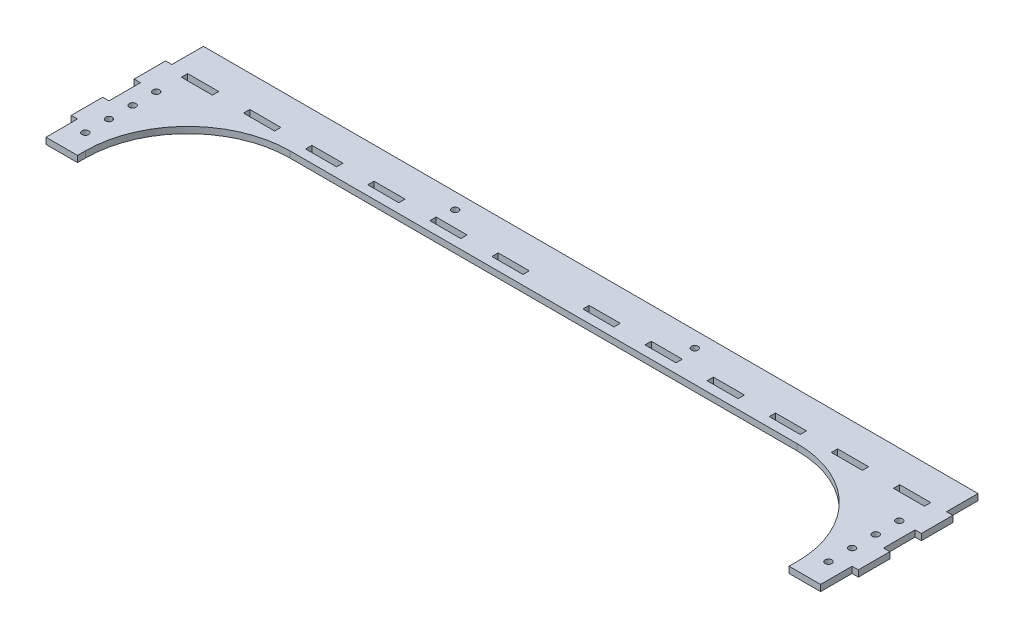
from build123d import *

# Parameters (mm, degrees)
SKETCH1_R           = 2.125
SKETCH1_W           = 19.725
SKETCH1_H           = 4
BOSS_EXTRUDE1_DEPTH = 4


with BuildPart() as part:
    # Sketch1 → Boss-Extrude1 (new body)
    with BuildSketch(Plane(origin=(0, 0, 0), x_dir=(1, 0, 0), z_dir=(0, 1, 0))):
        with BuildLine():
            Line((4, 0), (4, 20))
            Line((4, 20), (0, 20))
            Line((0, 20), (0, 40))
            Line((0, 40), (4, 40))
            Line((4, 40), (4, 60))
            Line((4, 60), (0, 60))
            Line((0, 60), (0, 80))
            Line((0, 80), (4, 80))
            Line((4, 80), (4, 100))
            Line((4, 100), (250, 100))
            Line((250, 100), (496, 100))
            Line((496, 100), (496, 80))
            Line((496, 80), (500, 80))
            Line((500, 80), (500, 60))
            Line((500, 60), (496, 60))
            Line((496, 60), (496, 40))
            Line((496, 40), (500, 40))
            Line((500, 40), (500, 20))
            Line((500, 20), (496, 20))
            Line((496, 20), (496, 0))
            Line((496, 0), (476, 0))
            Line((476, 0), (476, 5))
            ThreePointArc((476, 5), (456.961940777, 50.961940777), (411, 70))
            Line((411, 70), (89, 70))
            ThreePointArc((89, 70), (43.038059223, 50.961940777), (24, 5))
            Line((24, 5), (24, 0))
            Line((24, 0), (4, 0))
        make_face()
        with Locations((14, 15)):
            Circle(SKETCH1_R, mode=Mode.SUBTRACT)
        with Locations((14, 30)):
            Circle(SKETCH1_R, mode=Mode.SUBTRACT)
        with Locations((173.885, 90)):
            Circle(SKETCH1_R, mode=Mode.SUBTRACT)
        with Locations((326.115, 90)):
            Circle(SKETCH1_R, mode=Mode.SUBTRACT)
        with Locations((486, 30)):
            Circle(SKETCH1_R, mode=Mode.SUBTRACT)
        with Locations((486, 15)):
            Circle(SKETCH1_R, mode=Mode.SUBTRACT)
        with Locations((14, 60)):
            Circle(SKETCH1_R, mode=Mode.SUBTRACT)
        with Locations((14, 45)):
            Circle(SKETCH1_R, mode=Mode.SUBTRACT)
        with Locations((486, 45)):
            Circle(SKETCH1_R, mode=Mode.SUBTRACT)
        with Locations((486, 60)):
            Circle(SKETCH1_R, mode=Mode.SUBTRACT)
        with Locations((63.3125, 78)):
            Rectangle(SKETCH1_W, SKETCH1_H, mode=Mode.SUBTRACT)
        with Locations((23.8625, 78)):
            Rectangle(SKETCH1_W, SKETCH1_H, mode=Mode.SUBTRACT)
        with Locations((102.7625, 78)):
            Rectangle(SKETCH1_W, SKETCH1_H, mode=Mode.SUBTRACT)
        with Locations((142.2125, 78)):
            Rectangle(SKETCH1_W, SKETCH1_H, mode=Mode.SUBTRACT)
        with Locations((181.6625, 78)):
            Rectangle(SKETCH1_W, SKETCH1_H, mode=Mode.SUBTRACT)
        with Locations((221.1125, 78)):
            Rectangle(SKETCH1_W, SKETCH1_H, mode=Mode.SUBTRACT)
        with Locations((278.8875, 78)):
            Rectangle(SKETCH1_W, SKETCH1_H, mode=Mode.SUBTRACT)
        with Locations((318.3375, 78)):
            Rectangle(SKETCH1_W, SKETCH1_H, mode=Mode.SUBTRACT)
        with Locations((357.7875, 78)):
            Rectangle(SKETCH1_W, SKETCH1_H, mode=Mode.SUBTRACT)
        with Locations((397.2375, 78)):
            Rectangle(SKETCH1_W, SKETCH1_H, mode=Mode.SUBTRACT)
        with Locations((436.6875, 78)):
            Rectangle(SKETCH1_W, SKETCH1_H, mode=Mode.SUBTRACT)
        with Locations((476.1375, 78)):
            Rectangle(SKETCH1_W, SKETCH1_H, mode=Mode.SUBTRACT)
    extrude(amount=BOSS_EXTRUDE1_DEPTH)


solid = part.part
